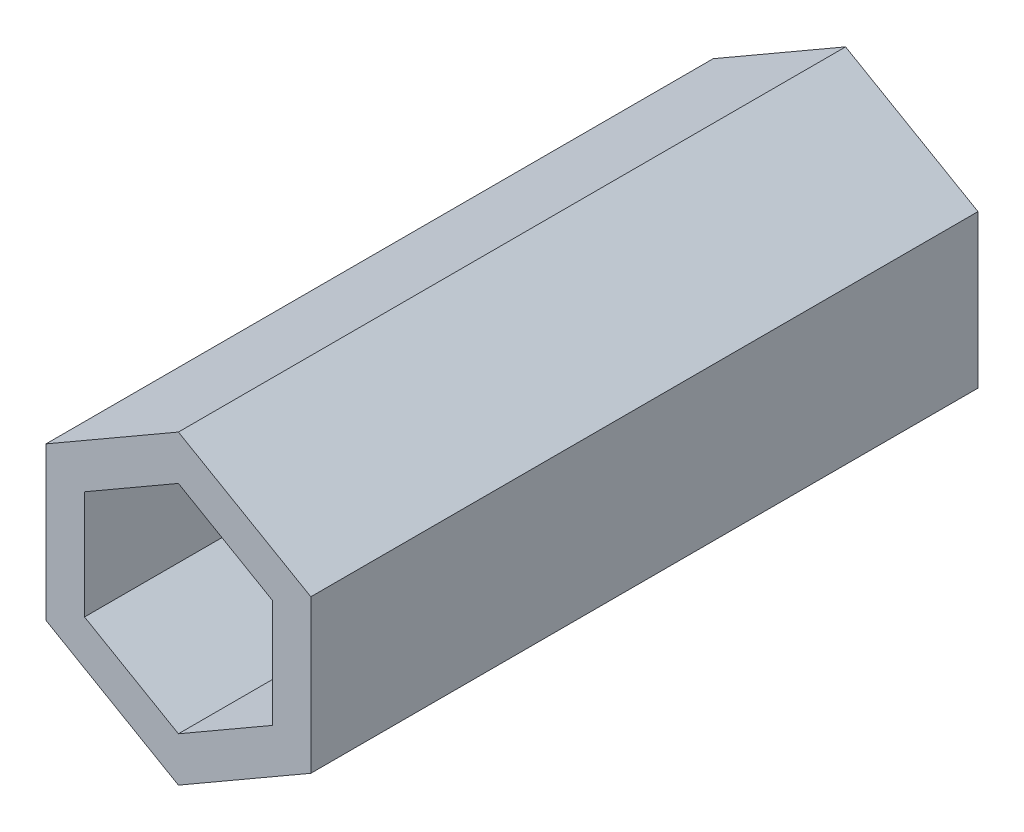
from build123d import *

# Parameters (mm, degrees)
BOSS_EXTRUDE2_DEPTH     = 24
CUT_EXTRUDE3_DEPTH      = 29.066884401
CUT_EXTRUDE3_DEPTH_BACK = 29.066884401


with BuildPart() as part:
    # Sketch1_3 → Boss-Extrude2 (new, symmetric)
    with BuildSketch(Plane.XY):
        Polygon((-9.526279442, -5.5), (0, -11), (9.526279442, -5.5), (9.526279442, 5.5), (0, 11), (-9.526279442, 5.5), align=None)
    extrude(amount=BOSS_EXTRUDE2_DEPTH, both=True)

    # Sketch2 → Cut-Extrude3 (cut, two sides: drawn at the far end of the back side and taken through both)
    with BuildSketch(Plane.XY.offset(-CUT_EXTRUDE3_DEPTH_BACK)):
        Polygon((0, -7.8), (6.75499815, -3.9), (6.75499815, 3.9), (0, 7.8), (-6.75499815, 3.9), (-6.75499815, -3.9), align=None)
    extrude(amount=CUT_EXTRUDE3_DEPTH + CUT_EXTRUDE3_DEPTH_BACK, mode=Mode.SUBTRACT)


solid = part.part
